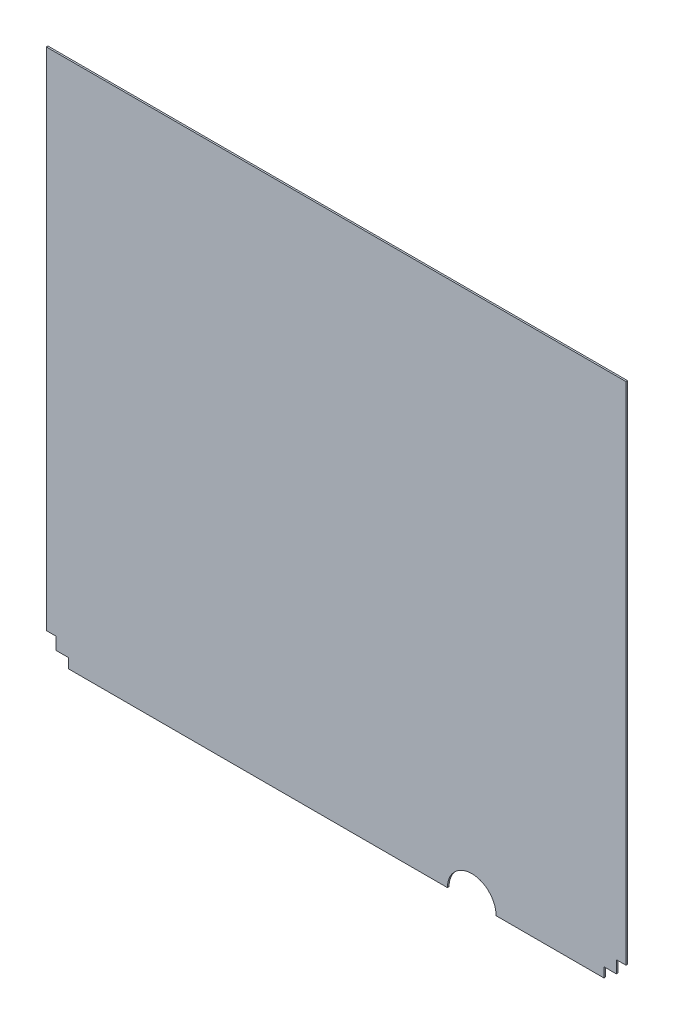
from build123d import *

# Parameters (mm, degrees)
BOSS_EXTRUDE1_DEPTH = 2.54


with BuildPart() as part:
    # Sketch1 → Boss-Extrude1 (new body)
    with BuildSketch(Plane.XY):
        with BuildLine():
            Line((0, 825.5), (0, 34.544))
            Line((0, 34.544), (15.24, 34.544))
            Line((15.24, 34.544), (15.24, 15.24))
            Line((15.24, 15.24), (34.544, 15.24))
            Line((34.544, 15.24), (34.544, 0))
            Line((34.544, 0), (627.60098, 0))
            ThreePointArc((627.60098, 0), (665.70098, 38.1), (703.80098, 0))
            Line((703.80098, 0), (872.45698, 0))
            Line((872.45698, 0), (872.45698, 15.24))
            Line((872.45698, 15.24), (891.76098, 15.24))
            Line((891.76098, 15.24), (891.76098, 34.544))
            Line((891.76098, 34.544), (907.00098, 34.544))
            Line((907.00098, 34.544), (907.00098, 825.5))
            Line((907.00098, 825.5), (0, 825.5))
        make_face()
    extrude(amount=BOSS_EXTRUDE1_DEPTH)


solid = part.part
